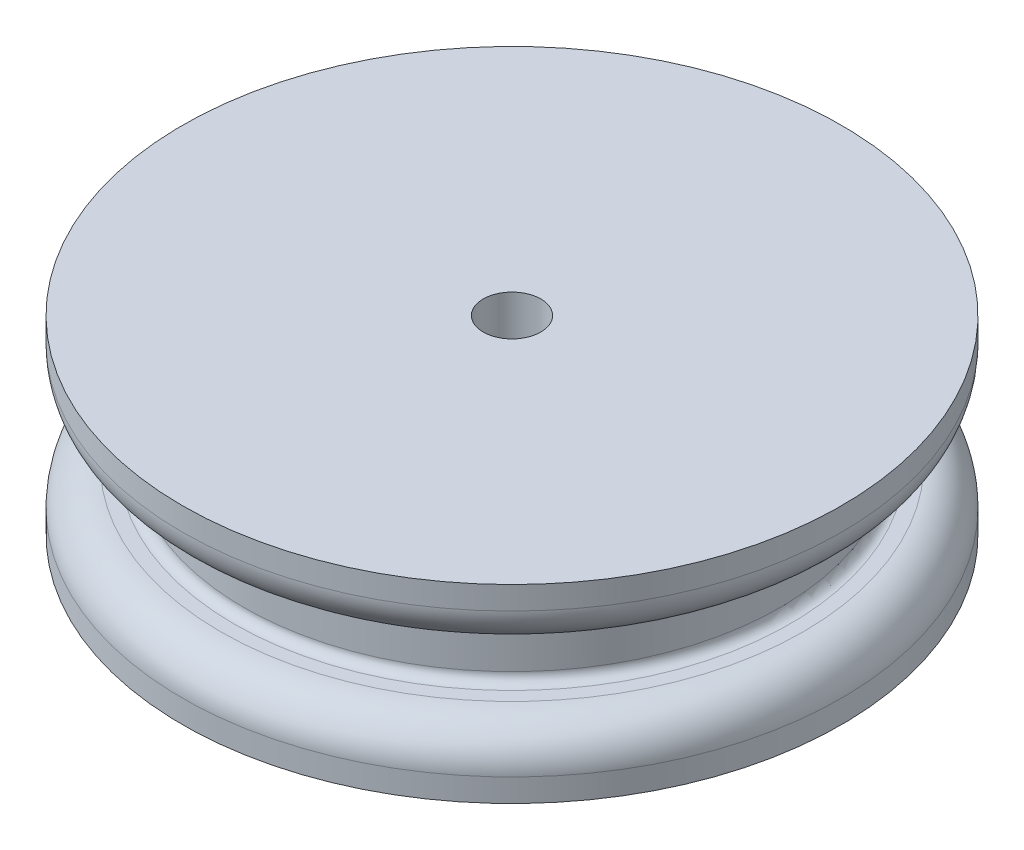
from build123d import *

# Parameters (mm, degrees)
CROQUIS1_R              = 14
SALIENTE_EXTRUIR1_DEPTH = 3.5
CROQUIS2_R              = 17.2
SALIENTE_EXTRUIR2_DEPTH = 3.2
CROQUIS3_R              = 17.2
SALIENTE_EXTRUIR3_DEPTH = 3.2
CROQUIS4_R              = 1.5
CORTAR_EXTRUIR1_DEPTH   = 10.9
REDONDEO1_R             = 2
REDONDEO2_R             = 0.5


with BuildPart() as part:
    # Croquis1 → Saliente-Extruir1 (new body)
    with BuildSketch(Plane(origin=(0, 0, 0), x_dir=(1, 0, 0), z_dir=(0, 1, 0))):
        Circle(CROQUIS1_R)
    extrude(amount=SALIENTE_EXTRUIR1_DEPTH)

    # Croquis2 → Saliente-Extruir2 (add)
    with BuildSketch(Plane(origin=(0, 3.5, 0), x_dir=(1, 0, 0), z_dir=(0, 1, 0))):
        Circle(CROQUIS2_R)
    extrude(amount=SALIENTE_EXTRUIR2_DEPTH)

    # Croquis3 → Saliente-Extruir3 (add)
    with BuildSketch(Plane.XZ):
        Circle(CROQUIS3_R)
    extrude(amount=SALIENTE_EXTRUIR3_DEPTH)

    # Croquis4 → Cortar-Extruir1 (cut, through all)
    with BuildSketch(Plane.XZ.offset(3.2)):
        Circle(CROQUIS4_R)
    extrude(amount=-CORTAR_EXTRUIR1_DEPTH, mode=Mode.SUBTRACT)

    # Redondeo1
    redondeo1_edges = [part.edges().sort_by_distance(p)[0] for p in [
        (-17.2, 0, 0),
        (-17.2, 3.5, 0),
    ]]
    fillet(redondeo1_edges, radius=REDONDEO1_R)

    # Redondeo2
    redondeo2_edges = [part.edges().sort_by_distance(p)[0] for p in [
        (-14, 0, 0),
        (-14, 3.5, 0),
    ]]
    fillet(redondeo2_edges, radius=REDONDEO2_R)


solid = part.part
